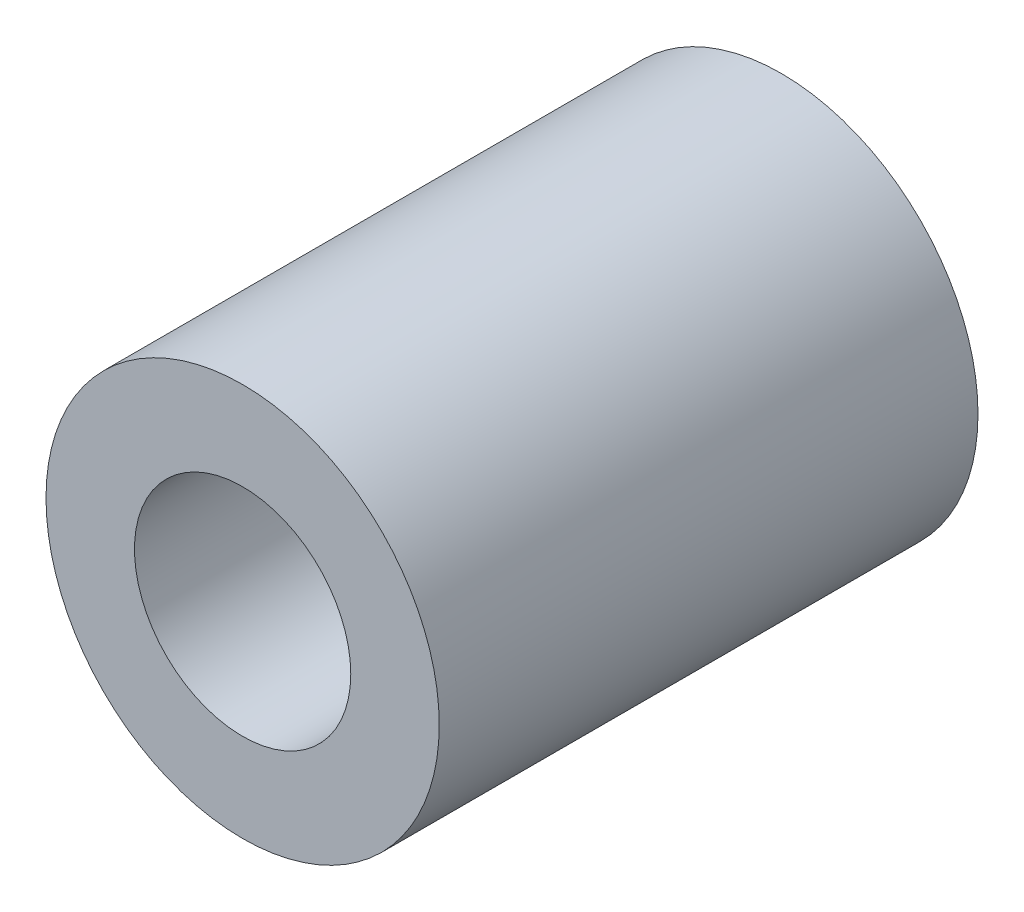
from build123d import *

# Parameters (mm, degrees)
SKETCH_1_R      = 5
SKETCH_1_R_2    = 2.75
EXTRUDE_1_DEPTH = 13.7


with BuildPart() as part:
    # ｽｹｯﾁ1 → ﾎﾞｽ - 押し出し1 (new body)
    with BuildSketch(Plane.XY):
        Circle(SKETCH_1_R)
        Circle(SKETCH_1_R_2, mode=Mode.SUBTRACT)
    extrude(amount=EXTRUDE_1_DEPTH)


solid = part.part
